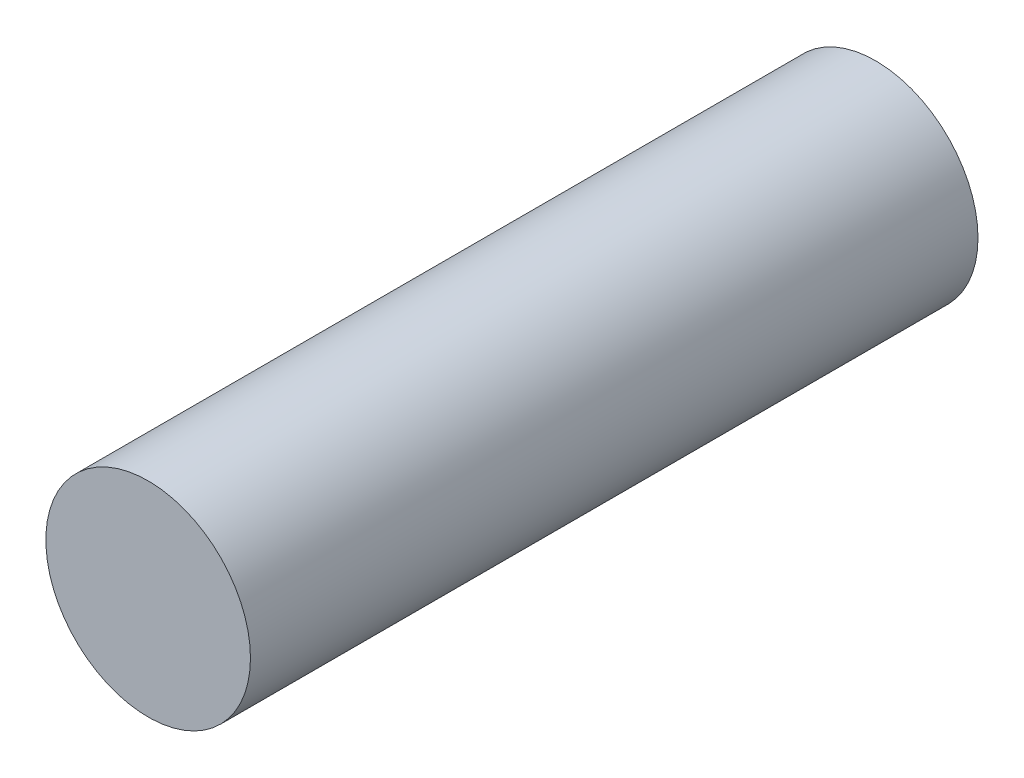
from build123d import *

# Parameters (mm, degrees)
SKETCH1_R           = 2.25
BOSS_EXTRUDE1_DEPTH = 16


with BuildPart() as part:
    # Sketch1 → Boss-Extrude1 (new body)
    with BuildSketch(Plane.XY):
        Circle(SKETCH1_R)
    extrude(amount=BOSS_EXTRUDE1_DEPTH)


solid = part.part
